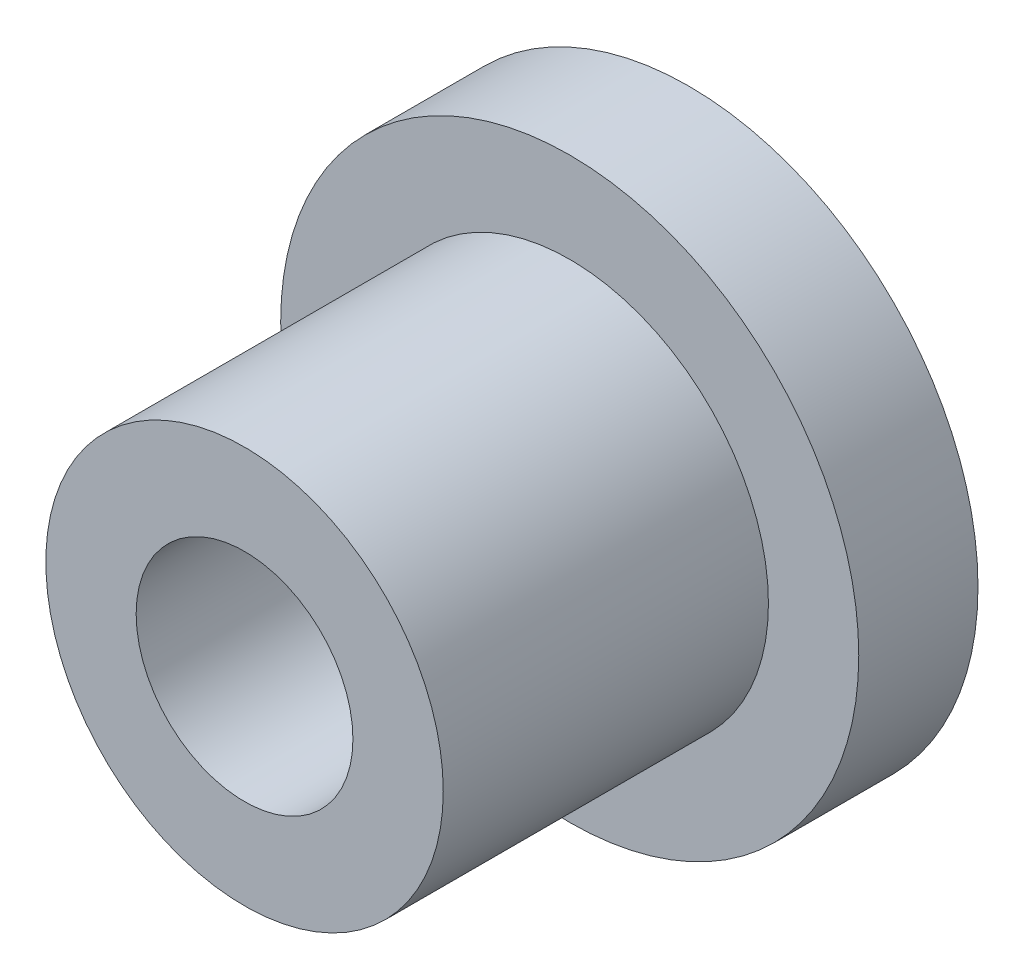
from build123d import *

# Parameters (mm, degrees)
SKETCH1_R           = 8
BOSS_EXTRUDE1_DEPTH = 3.3
SKETCH2_R           = 5.5
BOSS_EXTRUDE2_DEPTH = 9
SKETCH3_R           = 3
CUT_EXTRUDE3_DEPTH  = 4.3
CUT_EXTRUDE3_TAPER  = -45
SKETCH4_R           = 3
CUT_EXTRUDE4_DEPTH  = 13.3000001


with BuildPart() as part:
    # Sketch1 → Boss-Extrude1 (new body)
    with BuildSketch(Plane.XY):
        Circle(SKETCH1_R)
    extrude(amount=BOSS_EXTRUDE1_DEPTH)

    # Sketch2 → Boss-Extrude2 (add)
    with BuildSketch(Plane.XY.offset(3.3)):
        Circle(SKETCH2_R)
    extrude(amount=BOSS_EXTRUDE2_DEPTH)

    # Sketch3 → Cut-Extrude3 (cut, through all)
    with BuildSketch(Plane.XY.offset(3.3)):
        Circle(SKETCH3_R)
    extrude(amount=-CUT_EXTRUDE3_DEPTH, taper=CUT_EXTRUDE3_TAPER, mode=Mode.SUBTRACT)

    # Sketch4 → Cut-Extrude4 (cut, through all)
    with BuildSketch(Plane.XY.offset(12.3)):
        Circle(SKETCH4_R)
    extrude(amount=-CUT_EXTRUDE4_DEPTH, mode=Mode.SUBTRACT)


solid = part.part
